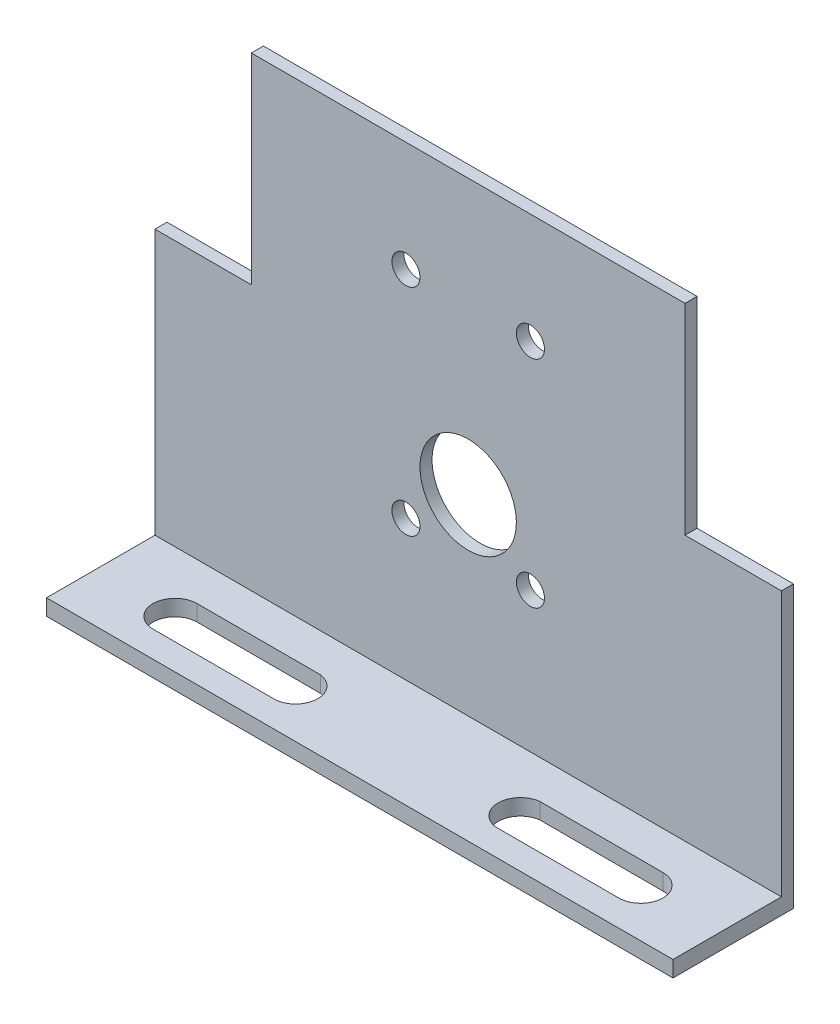
from build123d import *

# Parameters (mm, degrees)
SKETCH_1_R          = 6
SKETCH_1_R_2        = 1.75
EXTRUDE_1_DEPTH     = 1.5
SKETCH_2_W          = 78
SKETCH_2_H          = 2
EXTRUDE_2_DEPTH     = 15
CUT_EXTRUDE_1_DEPTH = 15


with BuildPart() as part:
    # 草图1 → 凸台-拉伸1 (new body)
    with BuildSketch(Plane.XY):
        Polygon((-78, 0), (0, 0), (0, 2), (0, 2.7366), (0, 35), (-12, 35), (-12, 60), (-66, 60), (-66, 35), (-78, 35), (-78, 2.7366), (-78, 2), align=None)
        with Locations((-39, 25.87)):
            Circle(SKETCH_1_R, mode=Mode.SUBTRACT)
        with Locations((-31.25, 19.445882155)):
            Circle(SKETCH_1_R_2, mode=Mode.SUBTRACT)
        with Locations((-46.75, 19.445882155)):
            Circle(SKETCH_1_R_2, mode=Mode.SUBTRACT)
        with Locations((-46.75, 46.292669673)):
            Circle(SKETCH_1_R_2, mode=Mode.SUBTRACT)
        with Locations((-31.25, 46.292669673)):
            Circle(SKETCH_1_R_2, mode=Mode.SUBTRACT)
    extrude(amount=EXTRUDE_1_DEPTH)

    # 草图2 → 凸台-拉伸2 (add)
    with BuildSketch(Plane(origin=(0, 0, 0), x_dir=(-1, 0, 0), z_dir=(0, 0, -1))):
        with Locations((39, 1)):
            Rectangle(SKETCH_2_W, SKETCH_2_H)
    extrude(amount=-EXTRUDE_2_DEPTH)

    # 草图3 → 切除-拉伸1 (cut)
    with BuildSketch(Plane.XZ):
        with BuildLine():
            Line((-68, 11.75), (-52.668833305, 11.75))
            ThreePointArc((-52.668833305, 11.75), (-50.230131523, 9), (-52.668833305, 6.25))
            Line((-52.668833305, 6.25), (-68, 6.25))
            ThreePointArc((-68, 6.25), (-70.75, 9), (-68, 11.75))
        make_face()
        with BuildLine():
            Line((-10, 6.25), (-25.331166695, 6.25))
            ThreePointArc((-25.331166695, 6.25), (-27.769868477, 9), (-25.331166695, 11.75))
            Line((-25.331166695, 11.75), (-10, 11.75))
            ThreePointArc((-10, 11.75), (-7.25, 9), (-10, 6.25))
        make_face()
    extrude(amount=-CUT_EXTRUDE_1_DEPTH, mode=Mode.SUBTRACT)


solid = part.part
